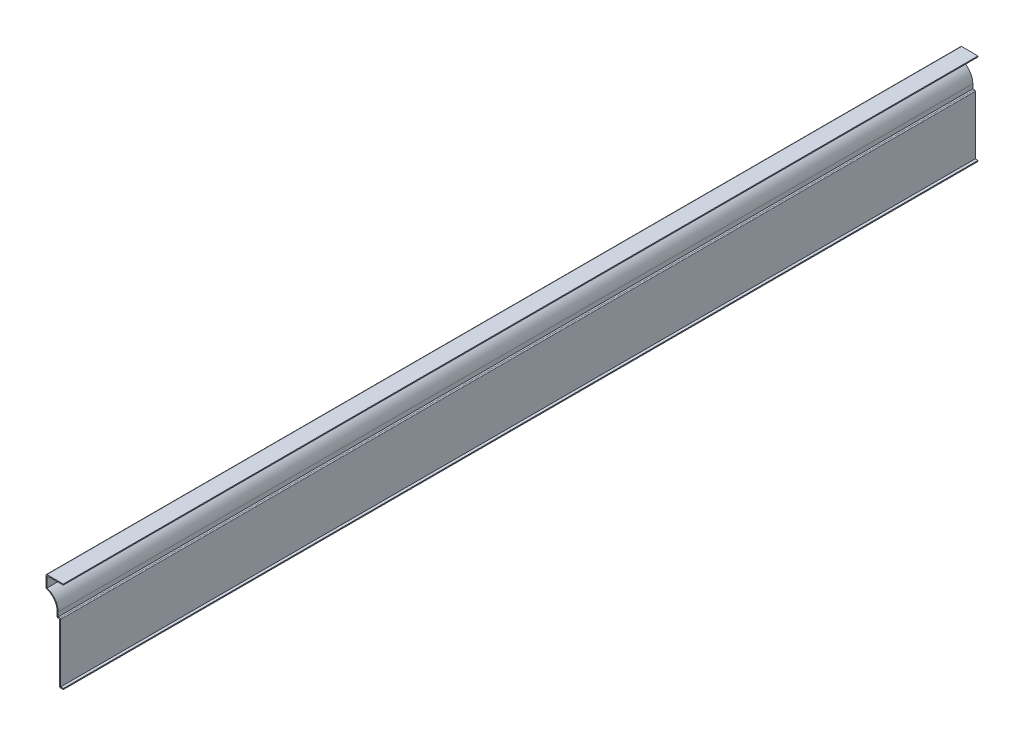
from build123d import *

# Parameters (mm, degrees)
EXTRUDE_THIN1_DEPTH = 1174.75
FILLET1_R           = 1.27


with BuildPart() as part:
    # Sketch1 → Extrude-Thin1 (new body)
    with BuildSketch(Plane.XY):
        with BuildLine():
            Line((0, 0), (-4.7625, 0))
            Line((-4.7625, 0), (-4.7625, 76.2))
            Line((-4.7625, 76.2), (-7.9375, 76.2))
            Line((-7.9375, 76.2), (-7.9375, 83.154916814))
            ThreePointArc((-7.9375, 83.154916814), (-11.927152643, 94.820611714), (-22.225, 101.6))
            Line((-22.225, 101.6), (-22.225, 117.475))
            Line((-22.225, 117.475), (0, 117.475))
            Line((0, 117.475), (0, 116.205))
            Line((0, 116.205), (-20.955, 116.205))
            Line((-20.955, 116.205), (-20.955, 102.558817034))
            ThreePointArc((-20.955, 102.558817034), (-10.624694617, 95.203194699), (-6.6675, 83.154916814))
            Line((-6.6675, 83.154916814), (-6.6675, 77.47))
            Line((-6.6675, 77.47), (-3.4925, 77.47))
            Line((-3.4925, 77.47), (-3.4925, 1.27))
            Line((-3.4925, 1.27), (0, 1.27))
            Line((0, 1.27), (0, 0))
        make_face()
    extrude(amount=-EXTRUDE_THIN1_DEPTH)

    # Fillet1
    fillet1_edges = [part.edges().sort_by_distance(p)[0] for p in [
        (-3.4925, 77.47, -587.375),
        (-4.7625, 0, -587.375),
        (-7.9375, 76.2, -587.375),
        (-22.225, 101.6, -587.375),
        (-22.225, 117.475, -587.375),
    ]]
    fillet(fillet1_edges, radius=FILLET1_R)


solid = part.part
